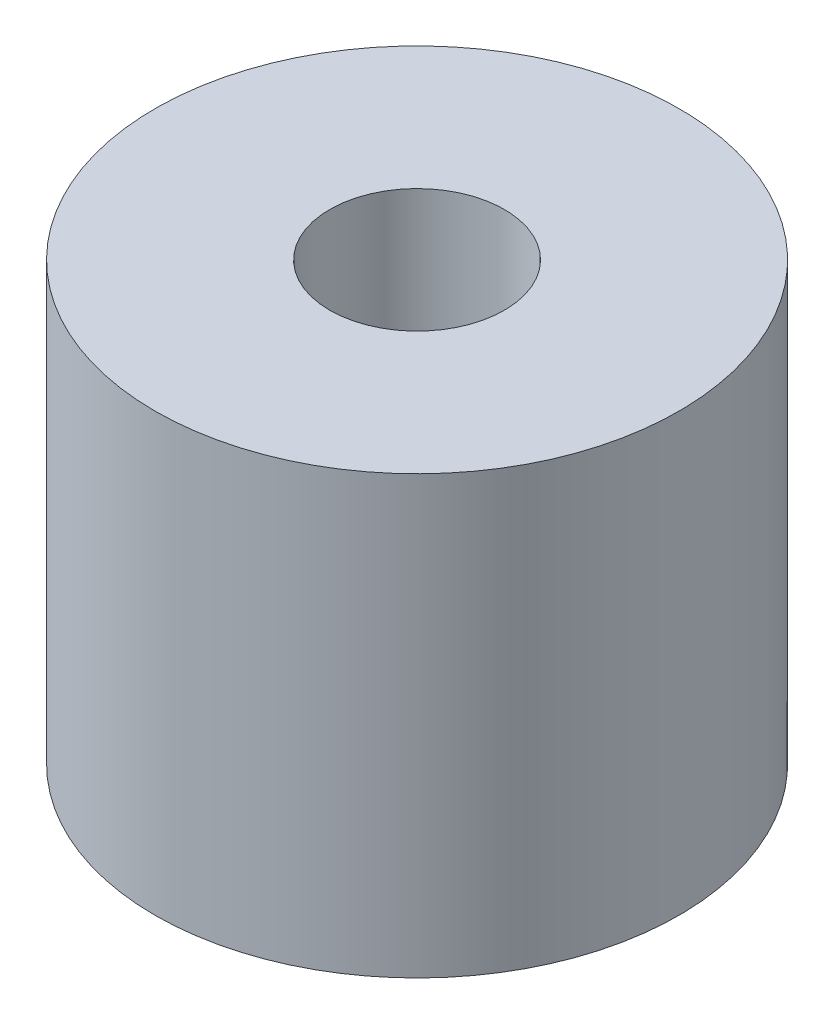
from build123d import *

# Parameters (mm, degrees)
SKETCH3_R           = 6
SKETCH3_R_2         = 2
BOSS_EXTRUDE2_DEPTH = 10


with BuildPart() as part:
    # Sketch3 → Boss-Extrude2 (new body)
    with BuildSketch(Plane(origin=(0, 0, 0), x_dir=(1, 0, 0), z_dir=(0, 1, 0))):
        Circle(SKETCH3_R)
        Circle(SKETCH3_R_2, mode=Mode.SUBTRACT)
    extrude(amount=BOSS_EXTRUDE2_DEPTH)


solid = part.part
